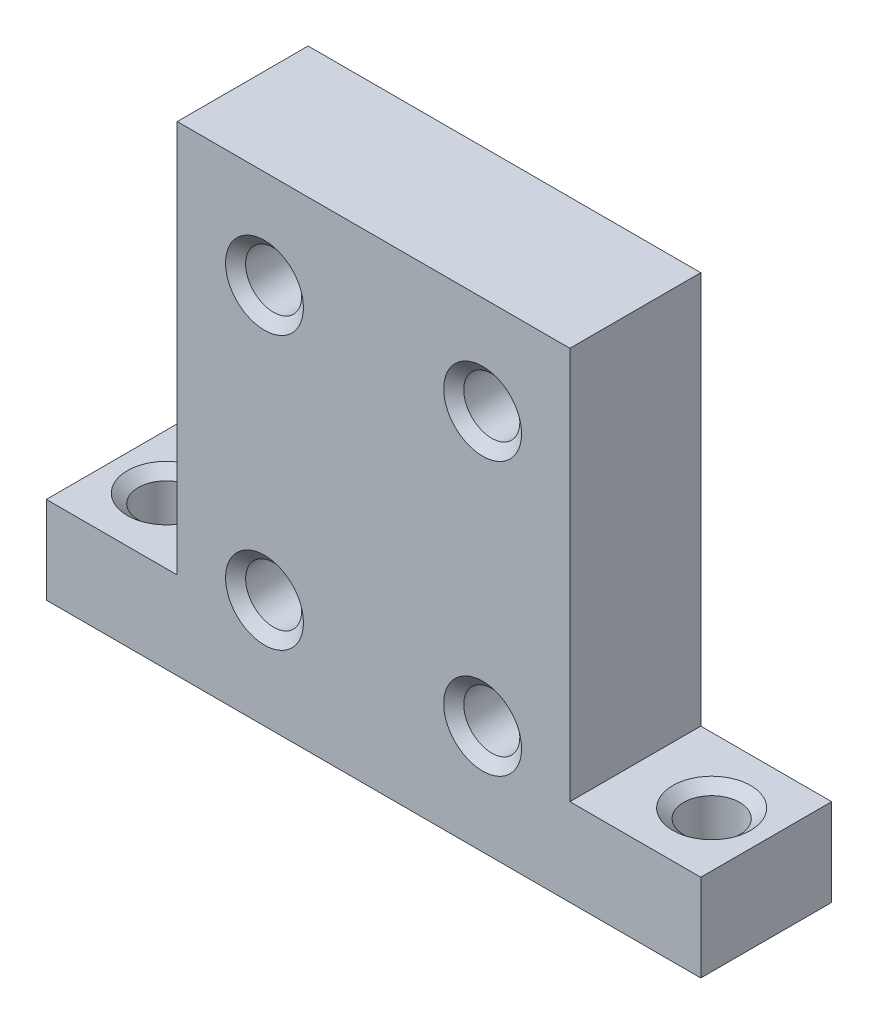
from build123d import *

# Parameters (mm, degrees)
SKETCH1_W                       = 38.1
SKETCH1_H                       = 7.62
BOSS_EXTRUDE1_DEPTH             = 5.08
SKETCH2_W                       = 22.86
SKETCH2_H                       = 7.62
BOSS_EXTRUDE2_DEPTH             = 22.86
F_4_CLEARANCE_HOLE1_D           = 3.2639
F_4_CLEARANCE_HOLE1_CSINK_D     = 4.5339
F_4_CLEARANCE_HOLE1_CSINK_ANGLE = 100
F_4_CLEARANCE_HOLE2_D           = 3.2639
F_4_CLEARANCE_HOLE2_CSINK_D     = 4.5339
F_4_CLEARANCE_HOLE2_CSINK_ANGLE = 100


with BuildPart() as part:
    # Sketch1 → Boss-Extrude1 (new body)
    with BuildSketch(Plane(origin=(0, 0, 0), x_dir=(1, 0, 0), z_dir=(0, 1, 0))):
        with Locations((-19.05, 3.81)):
            Rectangle(SKETCH1_W, SKETCH1_H)
    extrude(amount=BOSS_EXTRUDE1_DEPTH)

    # Sketch2 → Boss-Extrude2 (add)
    with BuildSketch(Plane(origin=(0, 5.08, 0), x_dir=(1, 0, 0), z_dir=(0, 1, 0))):
        with Locations((-19.05, 3.81)):
            Rectangle(SKETCH2_W, SKETCH2_H)
    extrude(amount=BOSS_EXTRUDE2_DEPTH)

    # #4 Clearance Hole1 (through all)
    with Locations(Plane(origin=(-25.4, 6.35, 0), x_dir=(1, 0, 0), z_dir=(0, 0, 1))):
        with Locations((0, 0), (0, 15.875), (12.7, 15.875), (12.7, 0)):
            CounterSinkHole(F_4_CLEARANCE_HOLE1_D / 2, F_4_CLEARANCE_HOLE1_CSINK_D / 2, counter_sink_angle=F_4_CLEARANCE_HOLE1_CSINK_ANGLE)

    # #4 Clearance Hole2 (through all)
    with Locations(Plane(origin=(0, 5.08, 0), x_dir=(1, 0, 0), z_dir=(0, 1, 0))):
        with Locations((-34.925, 3.81), (-3.175, 3.81)):
            CounterSinkHole(F_4_CLEARANCE_HOLE2_D / 2, F_4_CLEARANCE_HOLE2_CSINK_D / 2, counter_sink_angle=F_4_CLEARANCE_HOLE2_CSINK_ANGLE)


solid = part.part
